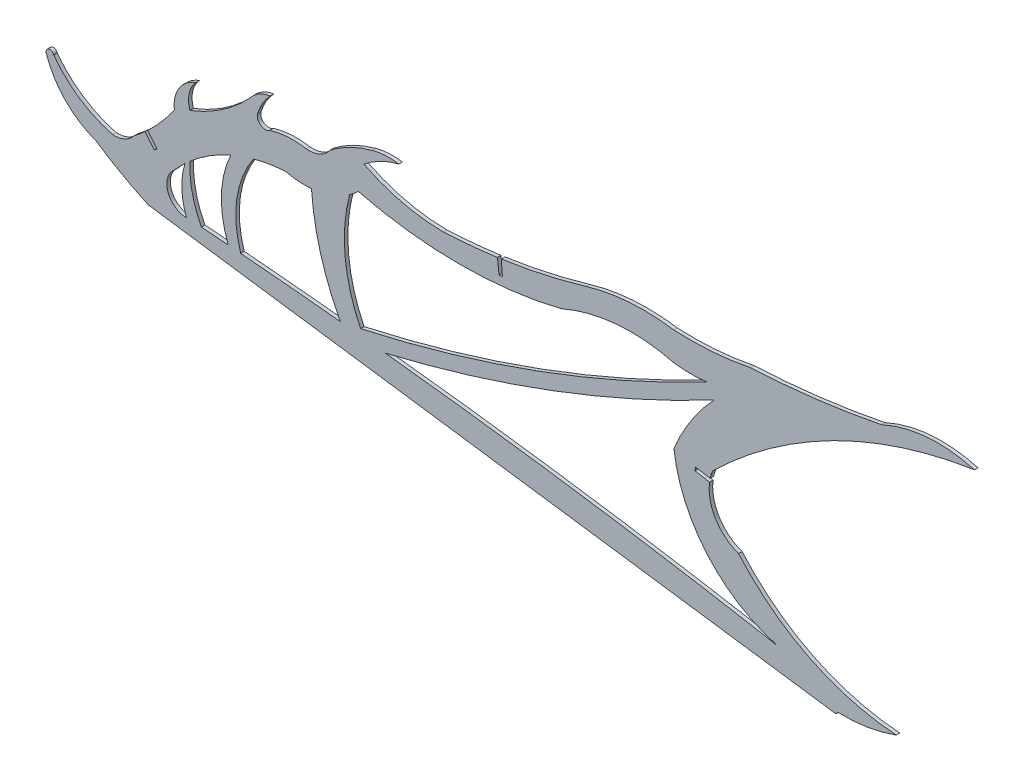
from build123d import *

# Parameters (mm, degrees)
BOSS_EXTRUDE1_DEPTH = 1.524
CUT_EXTRUDE1_DEPTH  = 1.524


with BuildPart() as part:
    # Sketch1 → Boss-Extrude1 (new body)
    with BuildSketch(Plane.XY):
        with BuildLine():
            Line((57.290824473, 228.108297044), (353.711488573, 186.321991739))
            ThreePointArc((353.711488573, 186.321991739), (354.075780486, 186.801693195), (354.433282196, 187.286476253))
            ThreePointArc((354.433282196, 187.286476253), (367.282944414, 188.133579217), (379.736207542, 191.411938565))
            ThreePointArc((379.736207542, 191.411938565), (342.378628376, 201.501430101), (311.755483248, 225.157497886))
            ThreePointArc((311.755483248, 225.157497886), (300.682282637, 235.370307227), (300.562470929, 250.433603398))
            ThreePointArc((300.562470929, 250.433603398), (321.044455039, 268.037495843), (343.59946469, 282.892806069))
            ThreePointArc((343.59946469, 282.892806069), (377.376618301, 298.266191923), (413.38768552, 307.235034456))
            ThreePointArc((413.38768552, 307.235034456), (393.078041438, 309.22946311), (373.338877641, 304.050196657))
            ThreePointArc((373.338877641, 304.050196657), (345.164765747, 299.513120241), (316.730515739, 297.09256867))
            ThreePointArc((316.730515739, 297.09256867), (300.377514826, 294.830345717), (283.869742792, 294.652149172))
            ThreePointArc((283.869742792, 294.652149172), (264.837645669, 295.417547796), (246.095409129, 292.02120779))
            ThreePointArc((246.095409129, 292.02120779), (215.671555063, 284.944519585), (184.616227681, 281.589366329))
            ThreePointArc((184.616227681, 281.589366329), (167.005302639, 283.674185668), (150.340503018, 289.738475081))
            ThreePointArc((150.340503018, 289.738475081), (157.435124743, 294.404562686), (165.406340408, 297.331293248))
            ThreePointArc((165.406340408, 297.331293248), (159.650281584, 297.625042258), (153.959513951, 296.711989461))
            ThreePointArc((153.959513951, 296.711989461), (144.425837897, 293.107350234), (135.76973662, 287.726243123))
            ThreePointArc((135.76973662, 287.726243123), (131.283660572, 283.993726612), (125.519570472, 283.081683228))
            ThreePointArc((125.519570472, 283.081683228), (117.575446144, 283.528434685), (109.74705726, 282.10540072))
            ThreePointArc((109.74705726, 282.10540072), (105.901175076, 281.967449489), (104.441699592, 285.528316185))
            ThreePointArc((104.441699592, 285.528316185), (106.645115294, 290.563839268), (109.921107262, 294.977387738))
            ThreePointArc((109.921107262, 294.977387738), (105.298186283, 293.444448732), (101.575381834, 290.304062227))
            ThreePointArc((101.575381834, 290.304062227), (89.522712553, 279.763084543), (75.355674106, 272.301578731))
            ThreePointArc((75.355674106, 272.301578731), (75.025286429, 278.530980407), (77.97930542, 284.025375103))
            ThreePointArc((77.97930542, 284.025375103), (70.672937053, 278.271974974), (68.631929607, 269.198997493))
            ThreePointArc((68.631929607, 269.198997493), (60.712120021, 259.329966949), (51.319192238, 250.850930717))
            ThreePointArc((51.319192238, 250.850930717), (47.204267049, 247.59528857), (42.038095614, 246.677417222))
            ThreePointArc((42.038095614, 246.677417222), (27.881645016, 252.981360845), (16.64661192, 263.65463729))
            ThreePointArc((16.64661192, 263.65463729), (14.473805053, 264.820038124), (13.469532472, 262.568219888))
            ThreePointArc((13.469532472, 262.568219888), (21.739819765, 249.170959745), (34.989718338, 240.66658328))
            ThreePointArc((34.989718338, 240.66658328), (45.889493734, 233.942107147), (57.290824473, 228.108297044))
        make_face()
        with BuildLine():
            ThreePointArc((328.489226954, 199.182421433), (244.252401976, 213.020971981), (159.578269796, 223.867146564))
            ThreePointArc((159.578269796, 223.867146564), (232.039463881, 246.03834442), (301.131135651, 277.159519764))
            ThreePointArc((301.131135651, 277.159519764), (291.304602068, 264.568913579), (283.869742792, 250.433603398))
            ThreePointArc((283.869742792, 250.433603398), (298.334085197, 217.977776055), (328.489226954, 199.182421433))
        make_face(mode=Mode.SUBTRACT)
        with BuildLine():
            ThreePointArc((73.889360105, 231.521400998), (65.868365727, 237.228895624), (68.631929607, 246.677417222))
            ThreePointArc((68.631929607, 246.677417222), (70.855224439, 249.097244695), (73.19077168, 251.408915949))
            ThreePointArc((73.19077168, 251.408915949), (71.867025962, 241.406389626), (73.889360105, 231.521400998))
        make_face(mode=Mode.SUBTRACT)
        with BuildLine():
            ThreePointArc((116.551068066, 270.179316334), (122.101400858, 269.279382121), (127.7241229, 269.312131715))
            ThreePointArc((127.7241229, 269.312131715), (131.669689581, 246.96106507), (140.187225602, 225.923259654))
            ThreePointArc((140.187225602, 225.923259654), (118.722956961, 228.014416663), (97.240833112, 229.913395557))
            ThreePointArc((97.240833112, 229.913395557), (95.566690644, 249.574533087), (102.786152544, 267.938695246))
            ThreePointArc((102.786152544, 267.938695246), (109.612083308, 269.406270814), (116.551068066, 270.179316334))
        make_face(mode=Mode.SUBTRACT)
        with BuildLine():
            ThreePointArc((147.854387632, 278.340365744), (191.622365865, 273.02026195), (235.390344097, 278.340365744))
            ThreePointArc((235.390344097, 278.340365744), (259.286439501, 284.470493189), (283.869742792, 282.405780779))
            ThreePointArc((283.869742792, 282.405780779), (290.901656942, 281.917548628), (297.936216355, 282.366058505))
            ThreePointArc((297.936216355, 282.366058505), (225.245012107, 250.01614522), (148.884216081, 227.665375775))
            ThreePointArc((148.884216081, 227.665375775), (142.212285393, 251.073648633), (144.166314335, 275.335628523))
            ThreePointArc((144.166314335, 275.335628523), (146.063284577, 276.773025404), (147.854387632, 278.340365744))
        make_face(mode=Mode.SUBTRACT)
        with BuildLine():
            ThreePointArc((92.963126534, 264.492689611), (88.906900231, 247.537272471), (91.873275106, 230.357640278))
            ThreePointArc((91.873275106, 230.357640278), (86.092526476, 230.822576823), (80.310675632, 231.273599578))
            ThreePointArc((80.310675632, 231.273599578), (76.354412107, 241.989032993), (75.355674106, 253.367743674))
            ThreePointArc((75.355674106, 253.367743674), (83.738923989, 259.595704551), (92.963126534, 264.492689611))
        make_face(mode=Mode.SUBTRACT)
    extrude(amount=BOSS_EXTRUDE1_DEPTH)

    # Sketch2 → Cut-Extrude1 (cut)
    with BuildSketch(Plane(origin=(0, 0, 0), x_dir=(-1, 0, 0), z_dir=(0, 0, -1))):
        Polygon((-293.228442315, 248.191486466), (-292.963264261, 246.690734455), (-301.831560839, 245.123734967), (-302.096738893, 246.624486978), align=None)
        Polygon((-210.010989789, 277.610431446), (-208.536964433, 277.452860551), (-207.725093618, 285.047652502), (-209.384282149, 285.202159423), align=None)
        Polygon((-61.191894588, 250.827806426), (-60.009228178, 249.866621656), (-54.939782062, 256.104198263), (-56.208453293, 256.959560494), align=None)
    extrude(amount=-CUT_EXTRUDE1_DEPTH, mode=Mode.SUBTRACT)


solid = part.part
